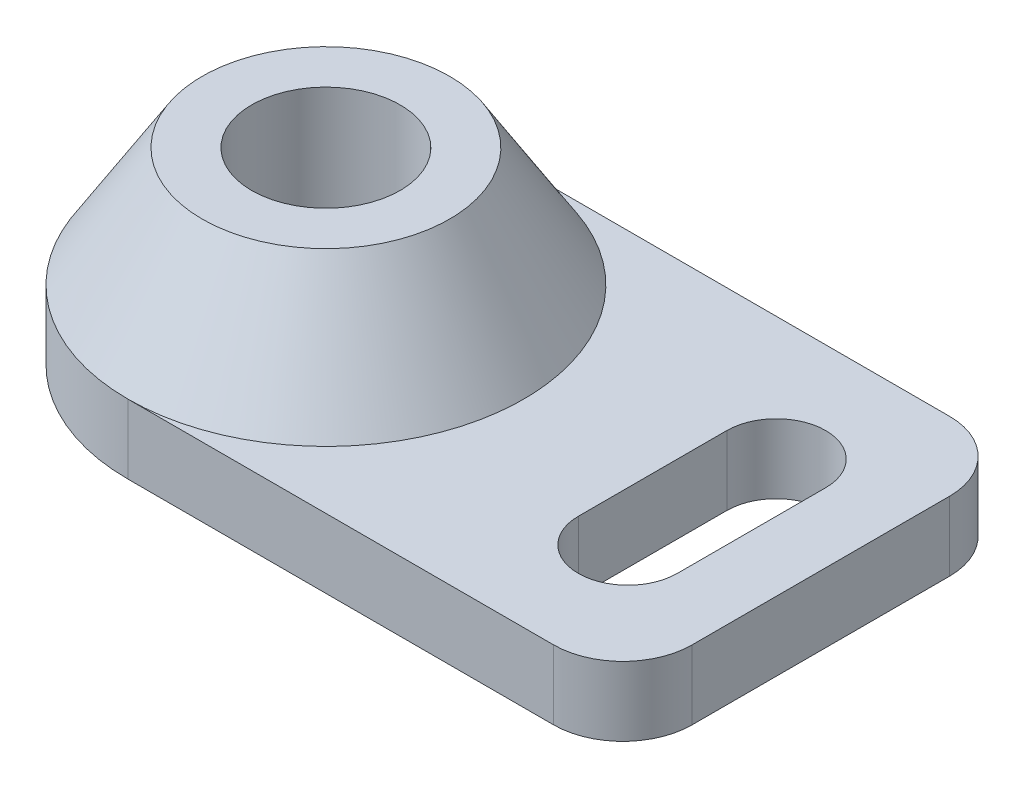
from build123d import *

# Parameters (mm, degrees)
BOSS_EXTRUDE1_DEPTH = 8.89
CUT_EXTRUDE2_DEPTH  = 8.89
FILLET1_R           = 8.89
SKETCH4_R           = 25.4
SKETCH11_R          = 15.875
SKETCH12_R          = 9.525
CUT_EXTRUDE3_DEPTH  = 25.13


with BuildPart() as part:
    # Sketch1 → Boss-Extrude1 (new body)
    with BuildSketch(Plane(origin=(0, 0, 0), x_dir=(1, 0, 0), z_dir=(0, 1, 0))):
        with BuildLine():
            Line((0, 0), (63.5, 0))
            Line((63.5, 0), (63.5, 50.8))
            Line((63.5, 50.8), (0, 50.8))
            ThreePointArc((0, 50.8), (-25.4, 25.4), (0, 0))
        make_face()
    extrude(amount=BOSS_EXTRUDE1_DEPTH)

    # Sketch2 → Cut-Extrude2 (cut)
    with BuildSketch(Plane(origin=(0, 8.89, 0), x_dir=(1, 0, 0), z_dir=(0, 1, 0))):
        with BuildLine():
            Line((41.91, 34.925), (41.91, 15.875))
            ThreePointArc((41.91, 15.875), (48.26, 9.525), (54.61, 15.875))
            Line((54.61, 15.875), (54.61, 34.925))
            ThreePointArc((54.61, 34.925), (48.26, 41.275), (41.91, 34.925))
        make_face()
    extrude(amount=-CUT_EXTRUDE2_DEPTH, mode=Mode.SUBTRACT)

    # Fillet1
    fillet1_edges = [part.edges().sort_by_distance(p)[0] for p in [
        (63.5, 4.445, -50.8),
        (63.5, 4.445, 0),
    ]]
    fillet(fillet1_edges, radius=FILLET1_R)

    # Sketch4 → Loft2 section 0
    with BuildSketch(Plane(origin=(0, 8.89, 0), x_dir=(1, 0, 0), z_dir=(0, 1, 0))):
        with Locations((0, 25.4)):
            Circle(SKETCH4_R)
    # Sketch11 → Loft2 section 1
    with BuildSketch(Plane(origin=(0, 24.13, 0), x_dir=(1, 0, 0), z_dir=(0, 1, 0))):
        with Locations((0, 25.4)):
            Circle(SKETCH11_R)
    loft()

    # Sketch12 → Cut-Extrude3 (cut, through all)
    with BuildSketch(Plane(origin=(0, 24.13, 0), x_dir=(1, 0, 0), z_dir=(0, 1, 0))):
        with Locations(Location((0, 25.4, 0), (0, 0, 270))):  # turned: the seam where the file's is
            Circle(SKETCH12_R)
    extrude(amount=-CUT_EXTRUDE3_DEPTH, mode=Mode.SUBTRACT)


solid = part.part
